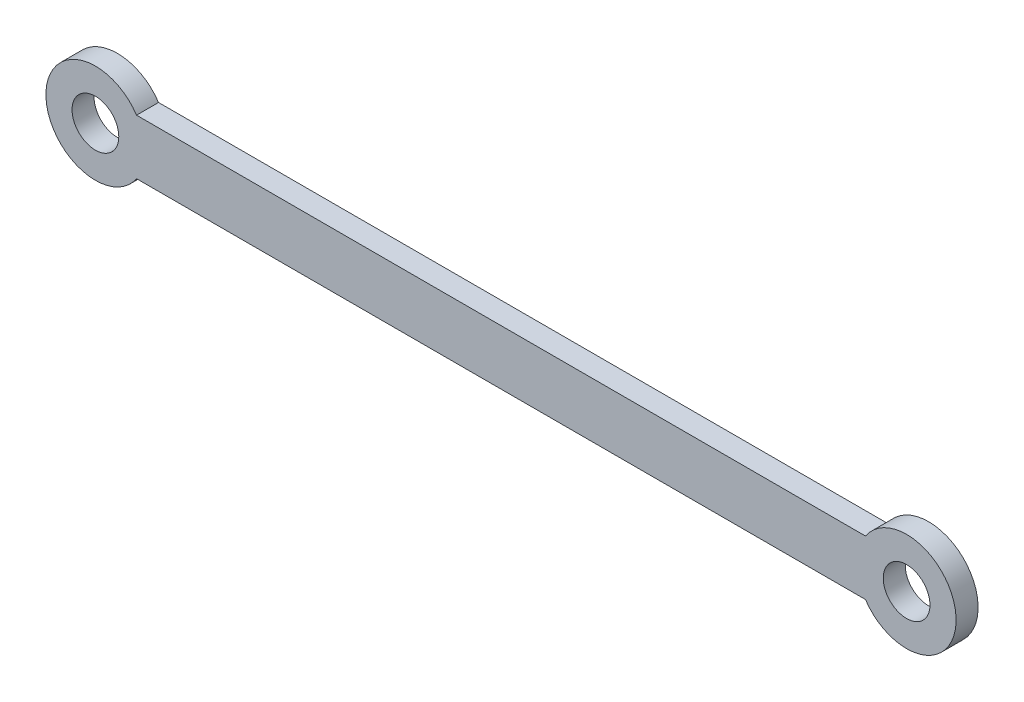
from build123d import *

# Parameters (mm, degrees)
SKETCH_1_R      = 4.25
EXTRUDE_1_DEPTH = 4


with BuildPart() as part:
    # 草图1 → 凸台-拉伸1 (new body)
    with BuildSketch(Plane.XY):
        with BuildLine():
            Line((7.483314774, 5), (140.016685226, 5))
            ThreePointArc((140.016685226, 5), (156.5, 0), (140.016685226, -5))
            Line((140.016685226, -5), (7.483314774, -5))
            ThreePointArc((7.483314774, -5), (-9, 0), (7.483314774, 5))
        make_face()
        Circle(SKETCH_1_R, mode=Mode.SUBTRACT)
        with Locations((147.5, 0)):
            Circle(SKETCH_1_R, mode=Mode.SUBTRACT)
    extrude(amount=EXTRUDE_1_DEPTH)


solid = part.part
